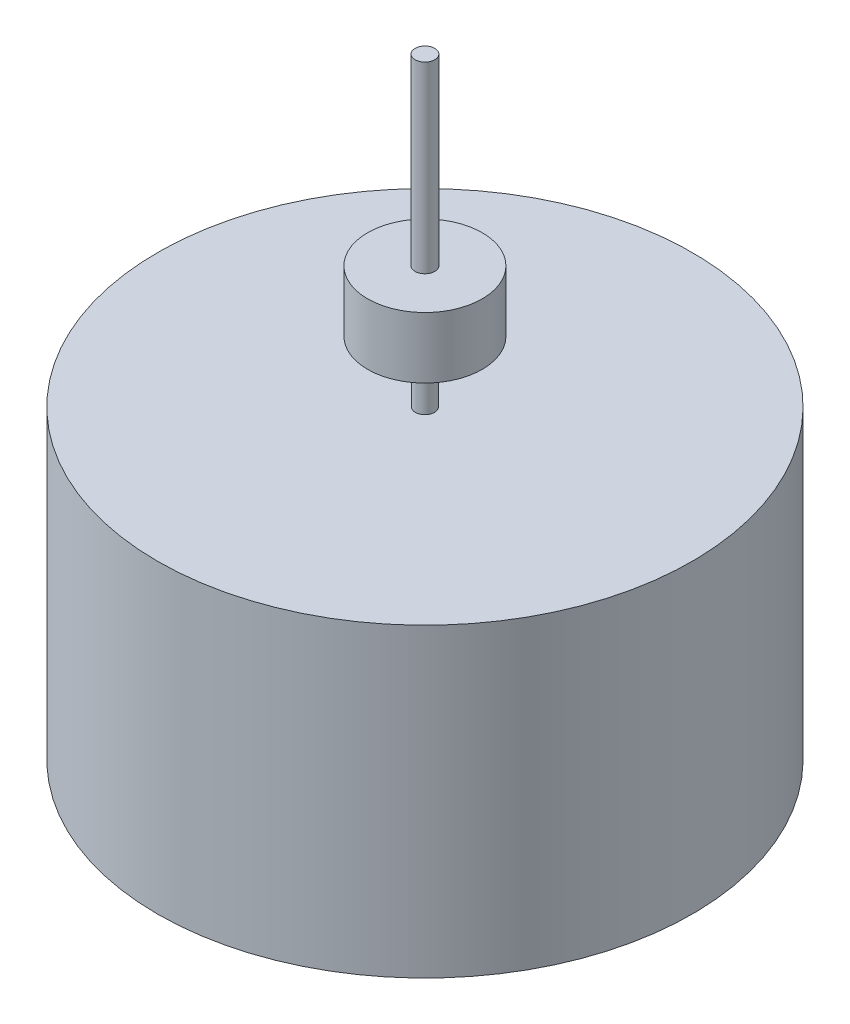
from build123d import *

# Parameters (mm, degrees)
SKETCH1_R           = 11.1125
BOSS_EXTRUDE1_DEPTH = 12.7
SKETCH2_R           = 0.396875
BOSS_EXTRUDE2_DEPTH = 2.54
SKETCH3_R           = 2.38125
BOSS_EXTRUDE3_DEPTH = 2.54
SKETCH4_R           = 0.409677419
BOSS_EXTRUDE4_DEPTH = 7.62


with BuildPart() as part:
    # Sketch1 → Boss-Extrude1 (new body)
    with BuildSketch(Plane(origin=(0, 0, 0), x_dir=(1, 0, 0), z_dir=(0, 1, 0))):
        Circle(SKETCH1_R)
    extrude(amount=BOSS_EXTRUDE1_DEPTH)

    # Sketch2 → Boss-Extrude2 (add)
    with BuildSketch(Plane(origin=(0, 12.7, 0), x_dir=(1, 0, 0), z_dir=(0, 1, 0))):
        Circle(SKETCH2_R)
    extrude(amount=BOSS_EXTRUDE2_DEPTH)

    # Sketch3 → Boss-Extrude3 (add)
    with BuildSketch(Plane(origin=(0, 15.24, 0), x_dir=(1, 0, 0), z_dir=(0, 1, 0))):
        Circle(SKETCH3_R)
    extrude(amount=BOSS_EXTRUDE3_DEPTH)

    # Sketch4 → Boss-Extrude4 (add)
    with BuildSketch(Plane(origin=(0, 17.78, 0), x_dir=(1, 0, 0), z_dir=(0, 1, 0))):
        Circle(SKETCH4_R)
    extrude(amount=BOSS_EXTRUDE4_DEPTH)


solid = part.part
